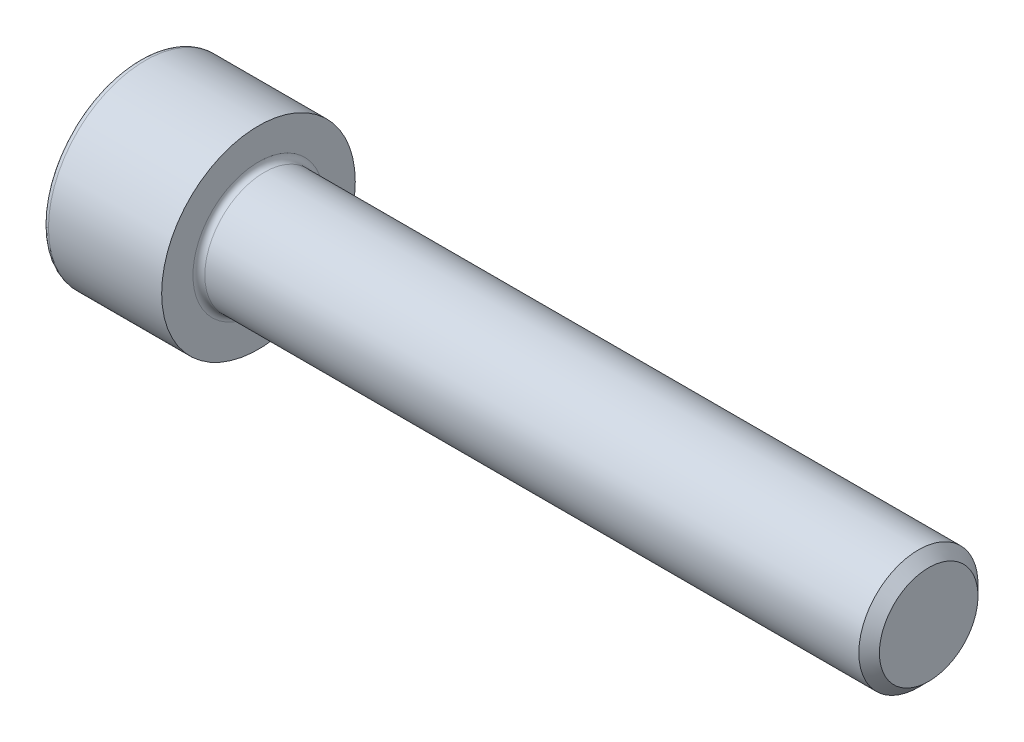
from build123d import *

# Parameters (mm, degrees)
FILLET1_R   = 0.4
FILLET2_R   = 0.4
HEX_2_DEPTH = 4


with BuildPart() as part:
    # BodySke → Base-Revolve (revolve)
    with BuildSketch(Plane.XY):
        Polygon((0, 0), (0, 6.5), (8, 6.5), (8, 4), (52.3095, 4), (53, 3.3095), (53, 0), align=None)
    revolve(axis=Axis((-31.75, 0, 0), (1, 0, 0)))

    # Fillet1
    fillet1_edges = [part.edges().sort_by_distance(p)[0] for p in [
        (8, -4, 0),
    ]]
    fillet(fillet1_edges, radius=FILLET1_R)

    # Fillet2
    fillet2_edges = [part.edges().sort_by_distance(p)[0] for p in [
        (0, -6.5, 0),
    ]]
    fillet(fillet2_edges, radius=FILLET2_R)

    # Sketch2 → Hex-PreBroach (revolve, cut)
    with BuildSketch(Plane.XY):
        Polygon((0, 3.0475), (4, 3.0475), (5.759474945, 0), (0, 0), align=None)
    revolve(axis=Axis((0, 0, 0), (1, 0, 0)), mode=Mode.SUBTRACT)

    # Sketch3 → Hex 2 (cut)
    with BuildSketch(Plane(origin=(0, 0, 0), x_dir=(0, 0.5, 0.866025404), z_dir=(-1, 0, 0))):
        Polygon((1.759474945, 3.0475), (-1.759474945, 3.0475), (-3.518949891, 0), (-1.759474945, -3.0475), (1.759474945, -3.0475), (3.518949891, 0), align=None)
    extrude(amount=-HEX_2_DEPTH, mode=Mode.SUBTRACT)


solid = part.part
